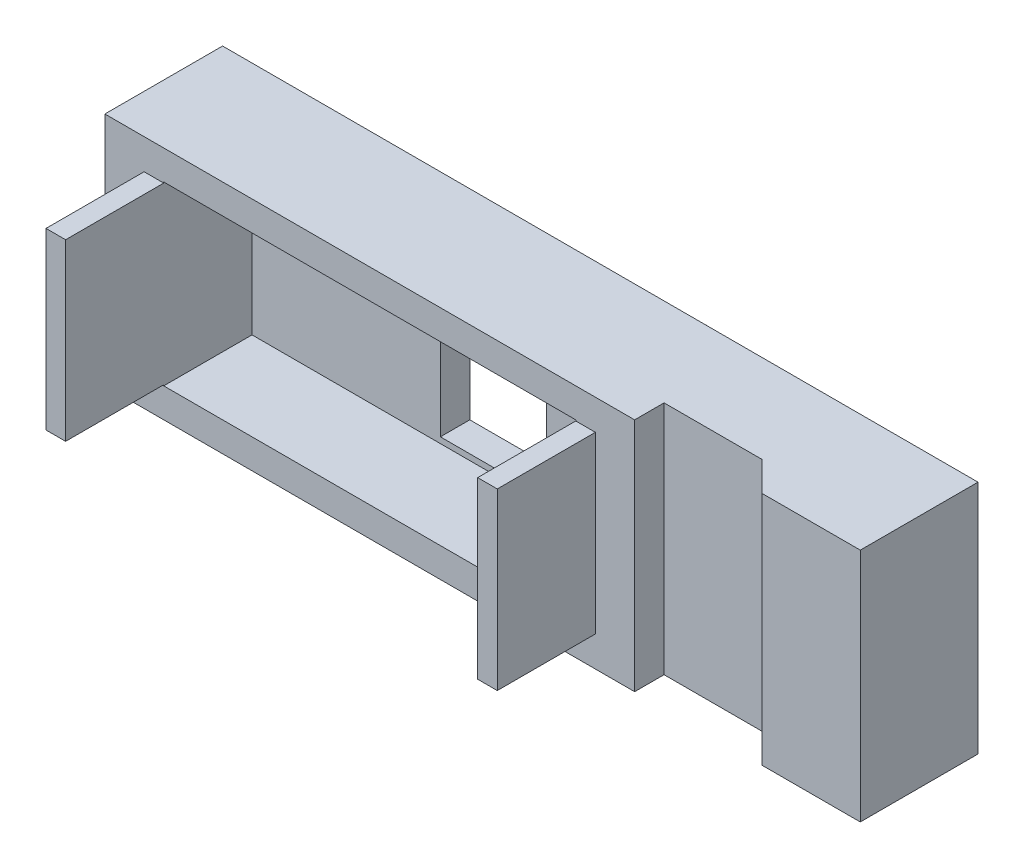
from build123d import *

# Parameters (mm, degrees)
SKETCH_1_W          = 27
SKETCH_1_H          = 12
SKETCH_1_W_2        = 21
SKETCH_1_H_2        = 9
EXTRUDE_1_DEPTH     = 6
SKETCH_2_W          = 21
SKETCH_2_H          = 9
EXTRUDE_2_DEPTH     = 1.5
SKETCH_3_W          = 5.4
SKETCH_3_H          = 8.2
CUT_EXTRUDE_1_DEPTH = 2.5
SKETCH_4_W          = 1
SKETCH_4_H          = 8.9
EXTRUDE_3_DEPTH     = 5
EXTRUDE_5_DEPTH     = 12
SKETCH_9_R          = 1.55
CUT_EXTRUDE_2_DEPTH = 3.5


with BuildPart() as part:
    # 草图1 → 凸台-拉伸1 (new body)
    with BuildSketch(Plane.XY):
        Rectangle(SKETCH_1_W, SKETCH_1_H)
        Rectangle(SKETCH_1_W_2, SKETCH_1_H_2, mode=Mode.SUBTRACT)
    extrude(amount=EXTRUDE_1_DEPTH)

    # 草图2 → 凸台-拉伸2 (add)
    with BuildSketch(Plane(origin=(0, 0, 0), x_dir=(-1, 0, 0), z_dir=(0, 0, -1))):
        Rectangle(SKETCH_2_W, SKETCH_2_H)
    extrude(amount=-EXTRUDE_2_DEPTH)

    # 草图3 → 切除-拉伸1 (cut, through all)
    with BuildSketch(Plane.XY.offset(1.5)):
        with Locations((1.8, -0.1)):
            Rectangle(SKETCH_3_W, SKETCH_3_H)
    extrude(amount=-CUT_EXTRUDE_1_DEPTH, mode=Mode.SUBTRACT)

    # 草图4 → 凸台-拉伸3 (add)
    with BuildSketch(Plane.XY.offset(6)):
        with Locations((-11, 0)):
            Rectangle(SKETCH_4_W, SKETCH_4_H)
        with Locations((11, 0)):
            Rectangle(SKETCH_4_W, SKETCH_4_H)
    extrude(amount=EXTRUDE_3_DEPTH)

    # 草图8 → 凸台-拉伸5 (add)
    with BuildSketch(Plane(origin=(0, 6, 0), x_dir=(1, 0, 0), z_dir=(0, 1, 0))):
        Polygon((13.5, -4.5), (18.5, -4.5), (20, -6), (25, -6), (25, 0), (20, 0), (13.5, 0), (13.5, -1.5), align=None)
    extrude(amount=-EXTRUDE_5_DEPTH)

    # 草图9 → 切除-拉伸2 (cut)
    with BuildSketch(Plane(origin=(0, 0, 0), x_dir=(-1, 0, 0), z_dir=(0, 0, -1))):
        with Locations((-22, 0)):
            Circle(SKETCH_9_R)
    extrude(amount=-CUT_EXTRUDE_2_DEPTH, mode=Mode.SUBTRACT)


solid = part.part
